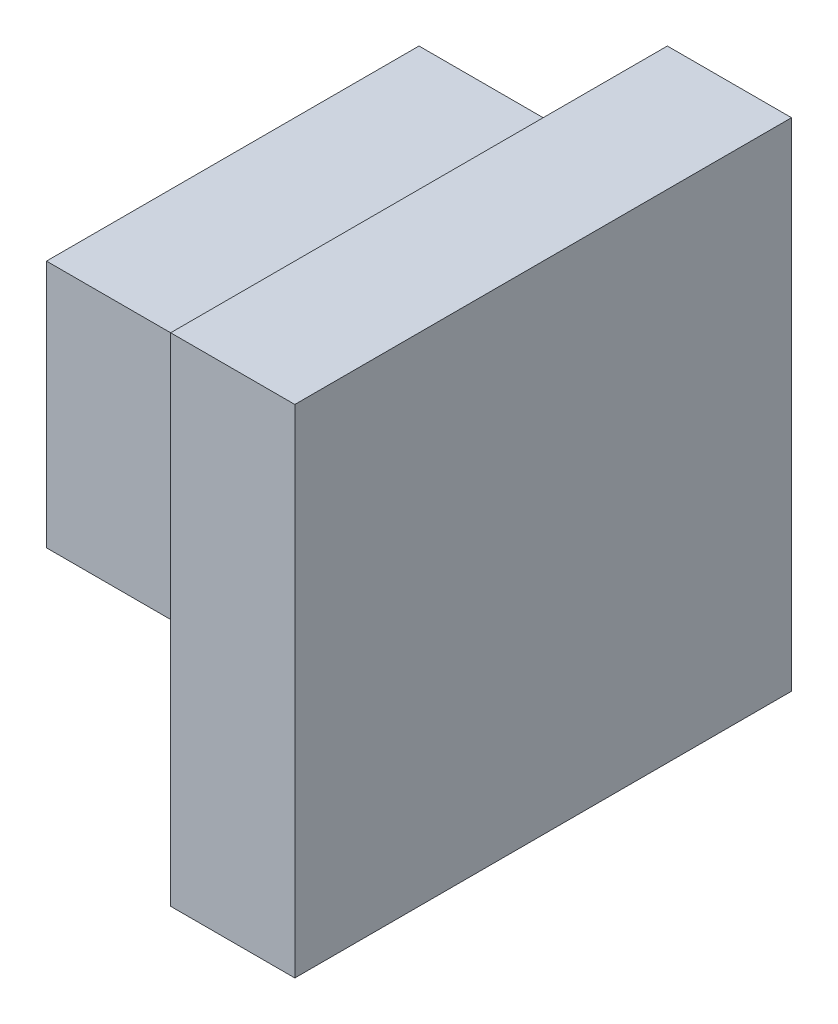
from build123d import *

# Parameters (mm, degrees)
BOSS_EXTRUDE1_DEPTH = 4
SKETCH2_W           = 1
SKETCH2_H           = 3
CUT_EXTRUDE1_DEPTH  = 2
SKETCH3_W           = 2
SKETCH3_H           = 3
CUT_EXTRUDE2_DEPTH  = 1


with BuildPart() as part:
    # Sketch1 → Boss-Extrude1 (new body)
    with BuildSketch(Plane.XY):
        Polygon((0, 0), (0, 2), (1, 2), (1, 3), (3, 3), (3, 4), (4, 4), (4, 0), (3, 0), (3, 1), (1, 1), (1, 0), align=None)
    extrude(amount=BOSS_EXTRUDE1_DEPTH)

    # Sketch2 → Cut-Extrude1 (cut)
    with BuildSketch(Plane.XY.offset(4)):
        with Locations((0.5, 1.5)):
            Rectangle(SKETCH2_W, SKETCH2_H)
    extrude(amount=-CUT_EXTRUDE1_DEPTH, mode=Mode.SUBTRACT)

    # Sketch3 → Cut-Extrude2 (cut)
    with BuildSketch(Plane.XY.offset(4)):
        with Locations((2, 1.5)):
            Rectangle(SKETCH3_W, SKETCH3_H)
    extrude(amount=-CUT_EXTRUDE2_DEPTH, mode=Mode.SUBTRACT)


solid = part.part
